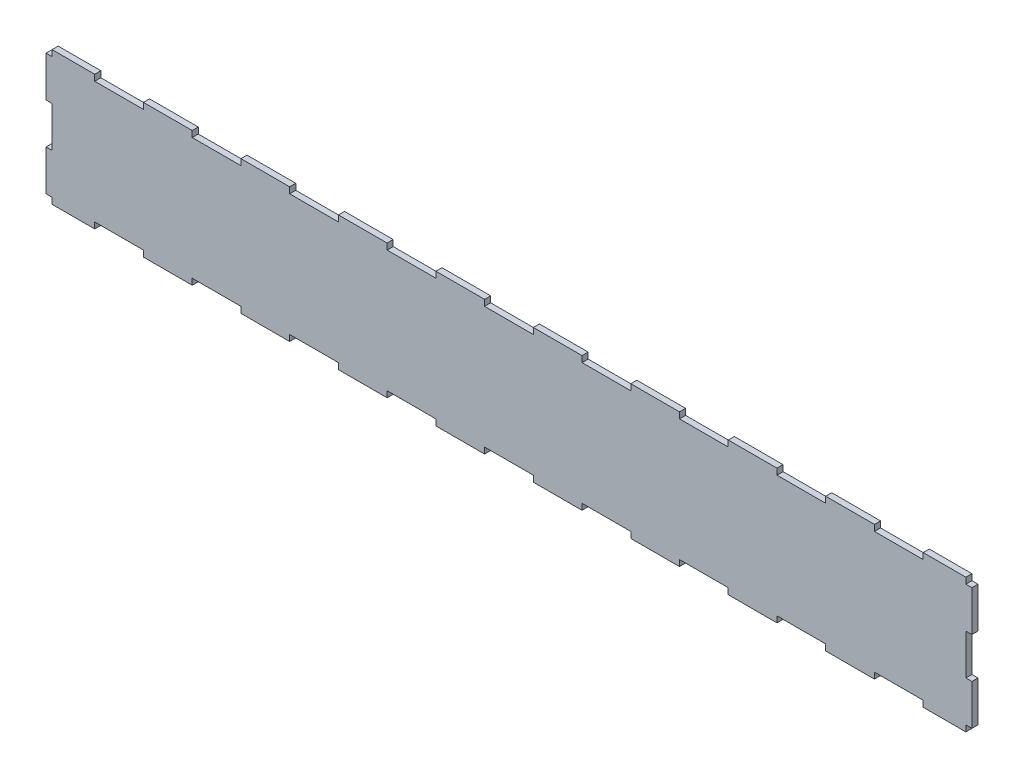
from build123d import *

# Parameters (mm, degrees)
BOSS_EXTRUDE1_DEPTH = 3
SKETCH3_W           = 3
SKETCH3_H           = 20
BOSS_EXTRUDE2_DEPTH = 3


with BuildPart() as part:
    # Sketch1 → Boss-Extrude1 (new body)
    with BuildSketch(Plane.XY):
        Polygon((-204, 9), (-204, 6), (-225, 6), (-225, 72), (-204, 72), (-204, 69), (-180, 69), (-180, 72), (-156, 72), (-156, 69), (-132, 69), (-132, 72), (-108, 72), (-108, 69), (-84, 69), (-84, 72), (-60, 72), (-60, 69), (-36, 69), (-36, 72), (-12, 72), (-12, 69), (12, 69), (12, 72), (36, 72), (36, 69), (60, 69), (60, 72), (84, 72), (84, 69), (108, 69), (108, 72), (132, 72), (132, 69), (156, 69), (156, 72), (180, 72), (180, 69), (204, 69), (204, 72), (225, 72), (225, 6), (204, 6), (204, 9), (180, 9), (180, 6), (156, 6), (156, 9), (132, 9), (132, 6), (108, 6), (108, 9), (84, 9), (84, 6), (60, 6), (60, 9), (36, 9), (36, 6), (12, 6), (12, 9), (-12, 9), (-12, 6), (-36, 6), (-36, 9), (-60, 9), (-60, 6), (-84, 6), (-84, 9), (-108, 9), (-108, 6), (-132, 6), (-132, 9), (-156, 9), (-156, 6), (-180, 6), (-180, 9), align=None)
    extrude(amount=BOSS_EXTRUDE1_DEPTH)

    # Sketch3 → Boss-Extrude2 (add)
    with BuildSketch(Plane.XY.offset(3)):
        with Locations((-226.5, 59)):
            Rectangle(SKETCH3_W, SKETCH3_H)
        with Locations((-226.5, 19)):
            Rectangle(SKETCH3_W, SKETCH3_H)
        with Locations((226.5, 59)):
            Rectangle(SKETCH3_W, SKETCH3_H)
        with Locations((226.5, 19)):
            Rectangle(SKETCH3_W, SKETCH3_H)
    extrude(amount=-BOSS_EXTRUDE2_DEPTH)


solid = part.part
